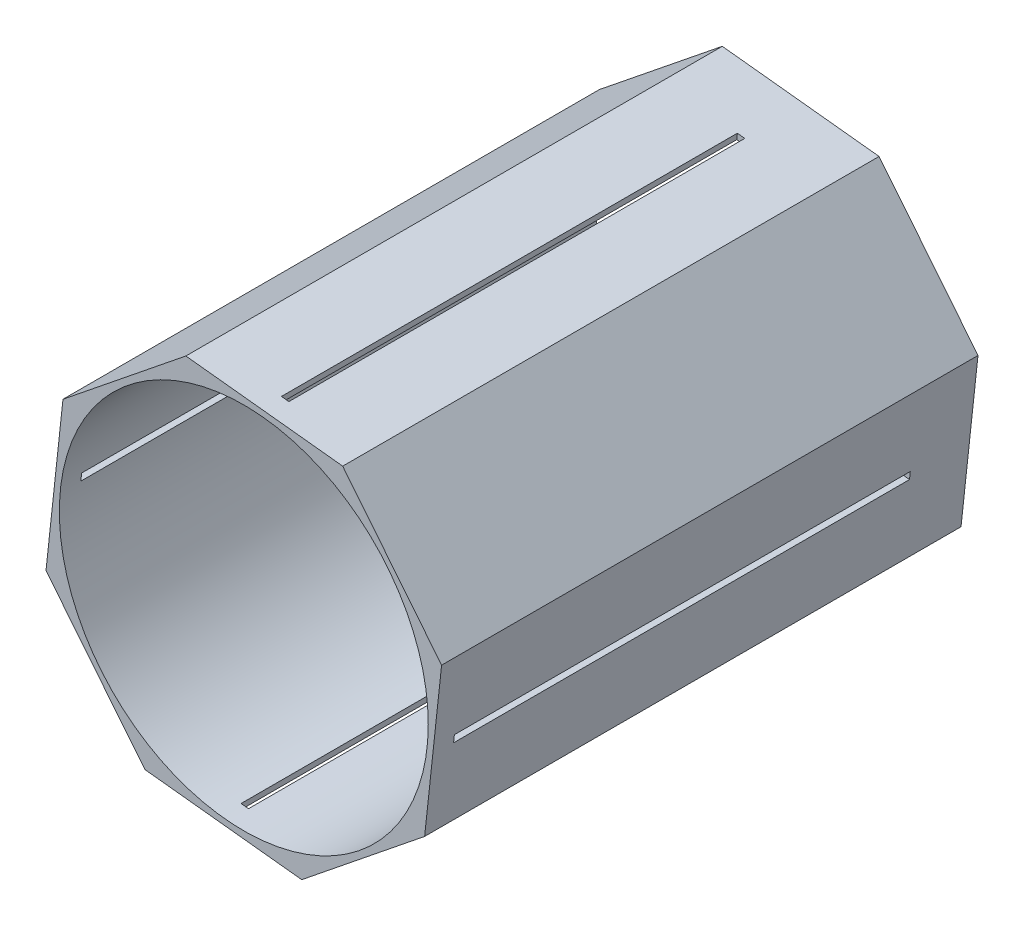
from build123d import *

# Parameters (mm, degrees)
SKETCH1_R           = 78.613
BOSS_EXTRUDE1_DEPTH = 228.6
SKETCH2_W           = 3.175
SKETCH2_H           = 194.31
CUT_EXTRUDE1_DEPTH  = 203.2
SKETCH5_W           = 194.31
SKETCH5_H           = 3.175
CUT_EXTRUDE2_DEPTH  = 203.2


with BuildPart() as part:
    # Sketch1 → Boss-Extrude1 (new body)
    with BuildSketch(Plane.XY):
        Polygon((77.066602343, -42.148481212), (84.297794001, 24.690840238), (42.148481212, 77.066602343), (-24.690840238, 84.297794001), (-77.066602343, 42.148481212), (-84.297794001, -24.690840238), (-42.148481212, -77.066602343), (24.690840238, -84.297794001), align=None)
        Circle(SKETCH1_R, mode=Mode.SUBTRACT)
    extrude(amount=BOSS_EXTRUDE1_DEPTH)

    # Sketch2 → Cut-Extrude1 (cut)
    with BuildSketch(Plane(origin=(8.728820487, 80.682198172, 0), x_dir=(0.99419859, -0.107560047, 0), z_dir=(0.107560047, 0.99419859, 0))):
        with Locations((0, -122.555)):
            Rectangle(SKETCH2_W, SKETCH2_H)
    extrude(amount=-CUT_EXTRUDE1_DEPTH, mode=Mode.SUBTRACT)

    # Sketch5 → Cut-Extrude2 (cut)
    with BuildSketch(Plane(origin=(-80.682198172, 8.728820487, 0), x_dir=(0, 0, 1), z_dir=(-0.99419859, 0.107560047, 0))):
        with Locations((122.555, 0)):
            Rectangle(SKETCH5_W, SKETCH5_H)
    extrude(amount=-CUT_EXTRUDE2_DEPTH, mode=Mode.SUBTRACT)


solid = part.part
